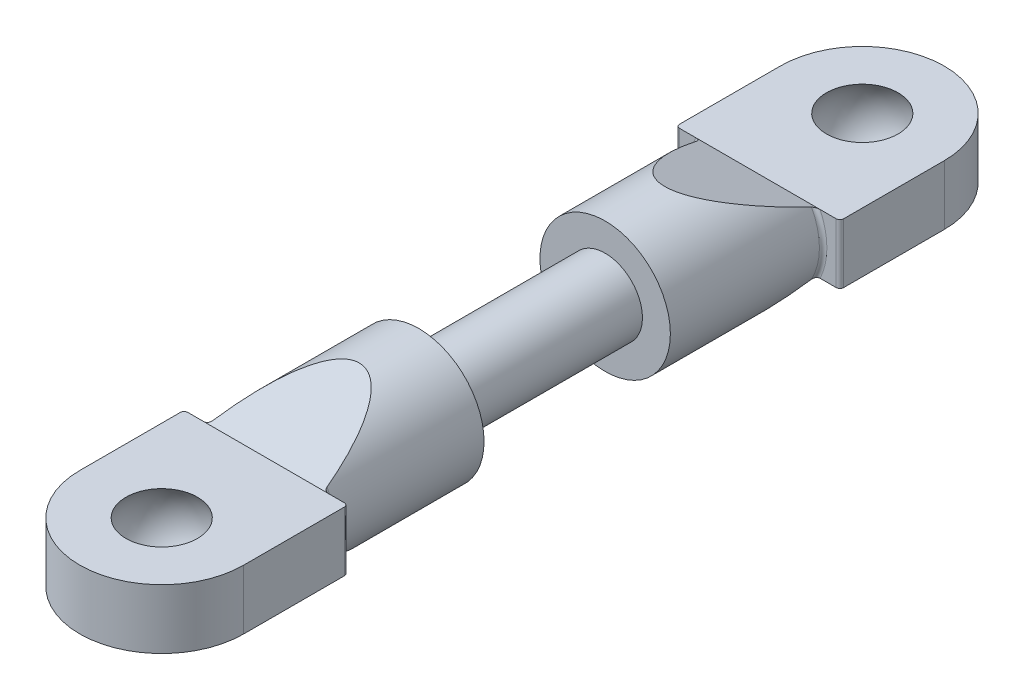
from build123d import *

# Parameters (mm, degrees)
SKETCH1_R                  = 2
SCREW_SECTION_DEPTH        = 5
SKETCH2_R                  = 3.5
BAR_SECTION_DEPTH          = 8.2
MOUNT_SECTION_DEPTH        = 1.6
BAR_TAPER_DEPTH            = 5.4
MOUNT_FILLET_R             = 0.2
MOUNT_FILLET_OF_MIRROR_2_R = 0.2


with BuildPart() as part:
    # Sketch1 → Screw Section (new body)
    with BuildSketch(Plane.XY):
        Circle(SKETCH1_R)
    screw_section = extrude(amount=SCREW_SECTION_DEPTH)

    # Sketch2 → Bar Section (add)
    with BuildSketch(Plane.XY.offset(5)):
        Circle(SKETCH2_R)
    bar_section = extrude(amount=BAR_SECTION_DEPTH)

    # Sketch3 → Mount Section (add, symmetric)
    with BuildSketch(Plane(origin=(0, 0, 0), x_dir=(1, 0, 0), z_dir=(0, 1, 0))):
        with BuildLine():
            Line((4.4, -13.2), (-4.4, -13.2))
            Line((-4.4, -13.2), (-4.4, -18.8))
            ThreePointArc((-4.4, -18.8), (0, -23.2), (4.4, -18.8))
            Line((4.4, -18.8), (4.4, -13.2))
        make_face()
    mount_section = extrude(amount=MOUNT_SECTION_DEPTH, both=True)

    # Sketch4 → Bar Taper (cut, symmetric)
    with BuildSketch(Plane(origin=(0, 0, 0), x_dir=(0, 0, -1), z_dir=(1, 0, 0))):
        Polygon((-8.2, -3.5), (-13.2, -1.6), (-13.2, -3.5), align=None)
        Polygon((-8.2, 3.5), (-13.2, 1.6), (-13.2, 3.5), align=None)
    bar_taper = extrude(amount=BAR_TAPER_DEPTH, both=True, mode=Mode.SUBTRACT)

    # Mount Fillet
    mount_fillet_edges = [part.edges().sort_by_distance(p)[0] for p in [
        (-4.4, 0, 13.2),
        (3.401842713, -0.823083322, 13.2),
        (-3.5, 0, 13.2),
        (4.4, 0, 13.2),
    ]]
    fillet(mount_fillet_edges, radius=MOUNT_FILLET_R)

    # Sketch6 → Ball Hole (revolve, cut)
    with BuildSketch(Plane(origin=(0, 0, 0), x_dir=(0, 0, -1), z_dir=(1, 0, 0))):
        with BuildLine():
            Line((-20.720937271, -1.6), (-18.8, -1.6))
            Line((-18.8, -1.6), (-18.8, 1.6))
            Line((-18.8, 1.6), (-20.720937271, 1.6))
            ThreePointArc((-20.720937271, 1.6), (-21.3, 0), (-20.720937271, -1.6))
        make_face()
    ball_hole = revolve(axis=Axis((0, -1.6, 18.8), (0, 1, 0)), mode=Mode.SUBTRACT)

    # Mirror 2: Screw Section, Bar Section, Mount Section, Bar Taper, Ball Hole across Front Plane
    add(screw_section.mirror(Plane.XY))
    add(bar_section.mirror(Plane.XY))
    add(mount_section.mirror(Plane.XY))
    add(bar_taper.mirror(Plane.XY), mode=Mode.SUBTRACT)
    add(ball_hole.mirror(Plane.XY), mode=Mode.SUBTRACT)

    # Mount Fillet of Mirror 2
    mount_fillet_of_mirror_2_edges = [part.edges().sort_by_distance(p)[0] for p in [
        (-4.4, 0, -13.2),
        (3.401842713, -0.823083322, -13.2),
        (-3.5, 0, -13.2),
        (4.4, 0, -13.2),
    ]]
    fillet(mount_fillet_of_mirror_2_edges, radius=MOUNT_FILLET_OF_MIRROR_2_R)


solid = part.part
